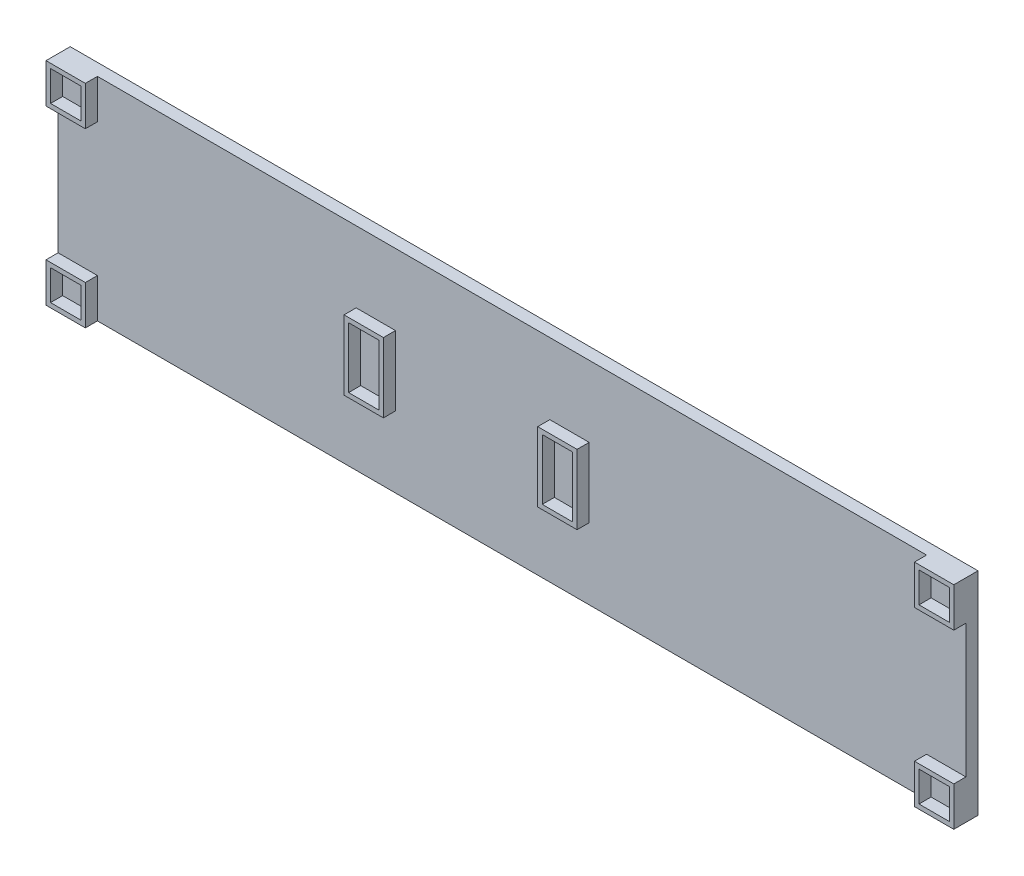
from build123d import *

# Parameters (mm, degrees)
SKICA1_W                = 150
SKICA1_H                = 35
P_IDAT_VYSUNUT_M2_DEPTH = 2
SKICA2_W                = 6.5
SKICA2_H                = 11.5
SKICA2_W_2              = 5
SKICA2_H_2              = 10
P_IDAT_VYSUNUT_M3_DEPTH = 2
SKICA3_W                = 6.5
SKICA3_H                = 6.5
SKICA3_W_2              = 5
SKICA3_H_2              = 5
P_IDAT_VYSUNUT_M4_DEPTH = 2


with BuildPart() as part:
    # Skica1 → Přidat vysunutím2 (new body)
    with BuildSketch(Plane.XY):
        Rectangle(SKICA1_W, SKICA1_H)
    extrude(amount=P_IDAT_VYSUNUT_M2_DEPTH)

    # Skica2 → Přidat vysunutím3 (add)
    with BuildSketch(Plane.XY.offset(2)):
        with Locations((-22.5, 0)):
            Rectangle(SKICA2_W, SKICA2_H)
        with Locations((-22.5, 0)):
            Rectangle(SKICA2_W_2, SKICA2_H_2, mode=Mode.SUBTRACT)
        with Locations((9.5, 0)):
            Rectangle(SKICA2_W, SKICA2_H)
        with Locations((9.5, 0)):
            Rectangle(SKICA2_W_2, SKICA2_H_2, mode=Mode.SUBTRACT)
    extrude(amount=P_IDAT_VYSUNUT_M3_DEPTH)

    # Skica3 → Přidat vysunutím4 (add)
    with BuildSketch(Plane.XY.offset(2)):
        with Locations((-71.75, 14.25)):
            Rectangle(SKICA3_W, SKICA3_H)
        with Locations((-71.75, 14.25)):
            Rectangle(SKICA3_W_2, SKICA3_H_2, mode=Mode.SUBTRACT)
        with Locations((71.75, 14.25)):
            Rectangle(SKICA3_W, SKICA3_H)
        with Locations((71.75, 14.25)):
            Rectangle(SKICA3_W_2, SKICA3_H_2, mode=Mode.SUBTRACT)
        with Locations((-71.75, -14.25)):
            Rectangle(SKICA3_W, SKICA3_H)
        with Locations((-71.75, -14.25)):
            Rectangle(SKICA3_W_2, SKICA3_H_2, mode=Mode.SUBTRACT)
        with Locations((71.75, -14.25)):
            Rectangle(SKICA3_W, SKICA3_H)
        with Locations((71.75, -14.25)):
            Rectangle(SKICA3_W_2, SKICA3_H_2, mode=Mode.SUBTRACT)
    extrude(amount=P_IDAT_VYSUNUT_M4_DEPTH)


solid = part.part
